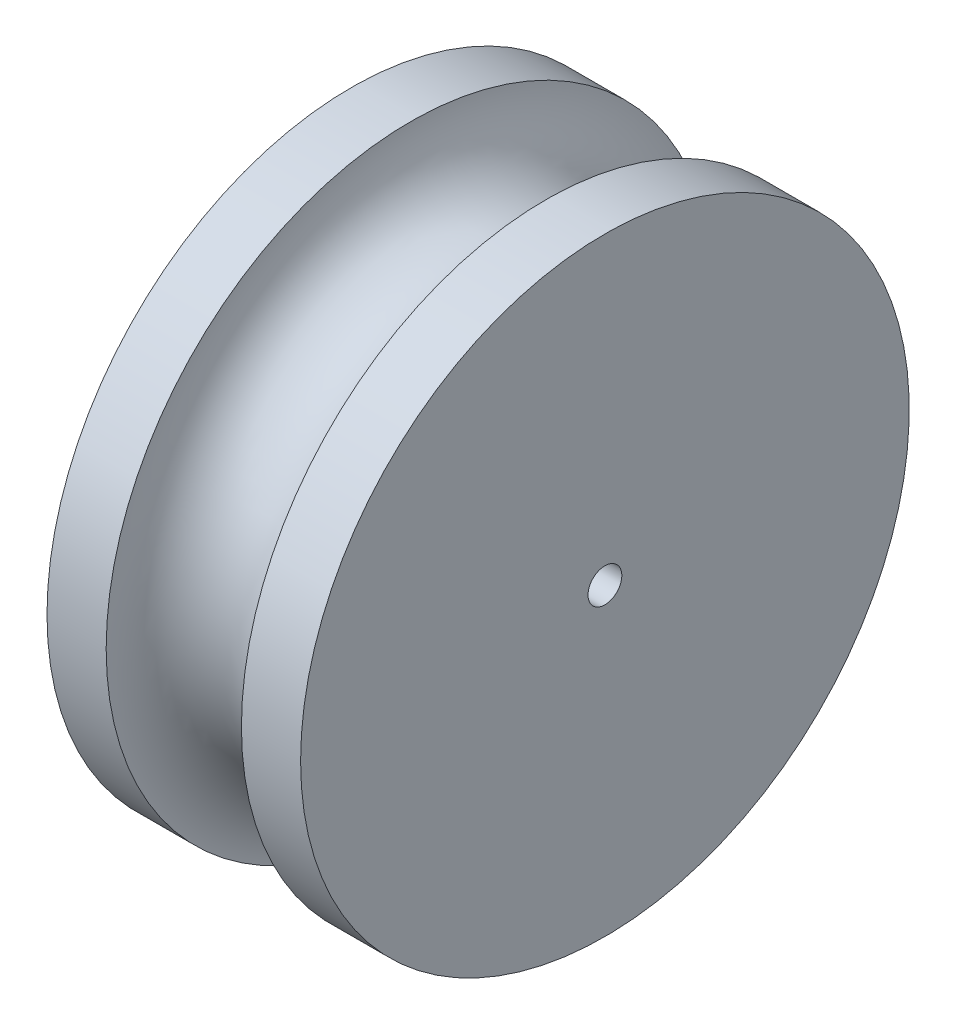
from build123d import *


with BuildPart() as part:
    # Sketch3 → Revolve1 (revolve)
    with BuildSketch(Plane(origin=(0, 0, 0), x_dir=(1, 0, 0), z_dir=(0, 1, 0))):
        with BuildLine():
            Line((-95.25, 12.7), (-95.25, 228.6))
            Line((-95.25, 228.6), (-50.8, 228.6))
            ThreePointArc((-50.8, 228.6), (0, 177.8), (50.8, 228.6))
            Line((50.8, 228.6), (95.25, 228.6))
            Line((95.25, 228.6), (95.25, 12.7))
            Line((95.25, 12.7), (-95.25, 12.7))
        make_face()
    revolve(axis=Axis((-3583.589553292, 0, 0), (1, 0, 0)))


solid = part.part
